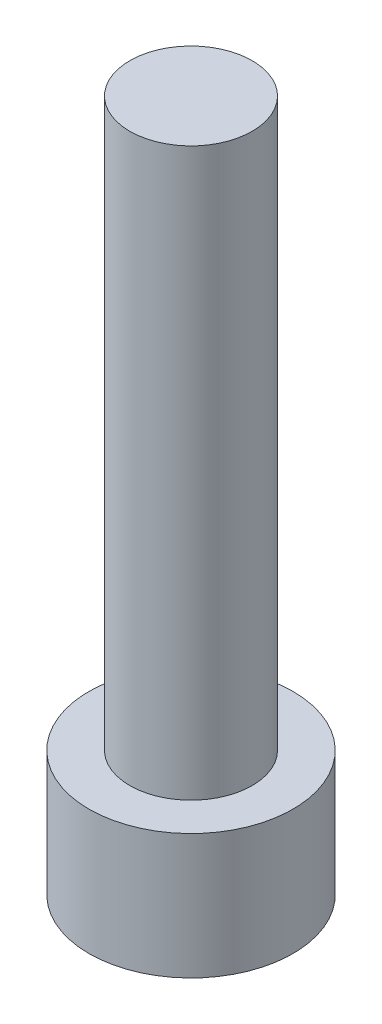
from build123d import *

# Parameters (mm, degrees)
SKETCH1_R           = 2.8575
BOSS_EXTRUDE1_DEPTH = 3.5052
CUT_EXTRUDE1_DEPTH  = 1.9558
SKETCH3_R           = 1.7145
BOSS_EXTRUDE2_DEPTH = 15.875


with BuildPart() as part:
    # Sketch1 → Boss-Extrude1 (new body)
    with BuildSketch(Plane(origin=(0, 0, 0), x_dir=(1, 0, 0), z_dir=(0, 1, 0))):
        Circle(SKETCH1_R)
    extrude(amount=BOSS_EXTRUDE1_DEPTH)

    # Sketch2 → Cut-Extrude1 (cut)
    with BuildSketch(Plane.XZ):
        Polygon((1.603951217, 0), (0.801975608, 1.3890625), (-0.801975608, 1.3890625), (-1.603951217, 0), (-0.801975608, -1.3890625), (0.801975608, -1.3890625), align=None)
    extrude(amount=-CUT_EXTRUDE1_DEPTH, mode=Mode.SUBTRACT)

    # Sketch3 → Boss-Extrude2 (add)
    with BuildSketch(Plane(origin=(0, 3.5052, 0), x_dir=(1, 0, 0), z_dir=(0, 1, 0))):
        Circle(SKETCH3_R)
    extrude(amount=BOSS_EXTRUDE2_DEPTH)


solid = part.part
